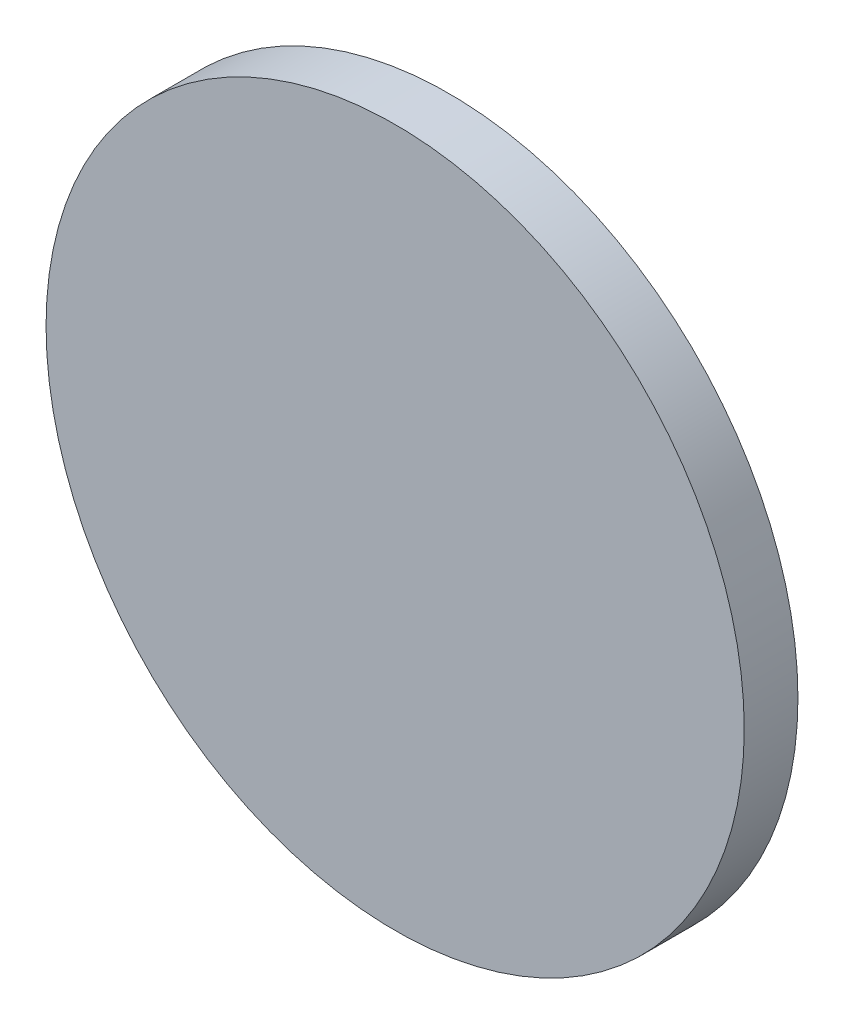
from build123d import *

# Parameters (mm, degrees)
SKETCH1_R           = 13
BOSS_EXTRUDE1_DEPTH = 2


with BuildPart() as part:
    # Sketch1 → Boss-Extrude1 (new body)
    with BuildSketch(Plane.XY):
        Circle(SKETCH1_R)
    extrude(amount=BOSS_EXTRUDE1_DEPTH)


solid = part.part
